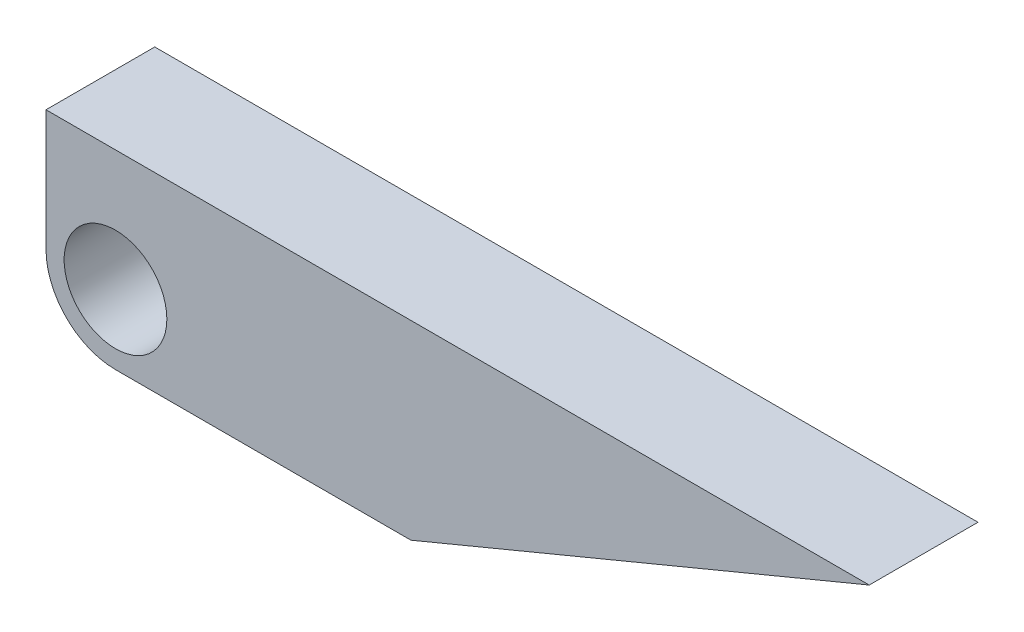
from build123d import *

# Parameters (mm, degrees)
SKETCH2_R           = 1.15
SKETCH2_R_2         = 0.85
BOSS_EXTRUDE1_DEPTH = 1.8


with BuildPart() as part:
    # Sketch2 → Boss-Extrude1 (new body)
    with BuildSketch(Plane.XY):
        Circle(SKETCH2_R)
        Circle(SKETCH2_R_2, mode=Mode.SUBTRACT)
        with BuildLine():
            Line((-1.15, 2), (-1.15, 0))
            ThreePointArc((-1.15, 0), (0, 1.15), (1.15, 0))
            ThreePointArc((1.15, 0), (0.813172798, -0.813172798), (0, -1.15))
            Line((0, -1.15), (4.889316376, -1.15))
            Line((4.889316376, -1.15), (12.47489452, 2))
            Line((12.47489452, 2), (-1.15, 2))
        make_face()
    extrude(amount=BOSS_EXTRUDE1_DEPTH)


solid = part.part
